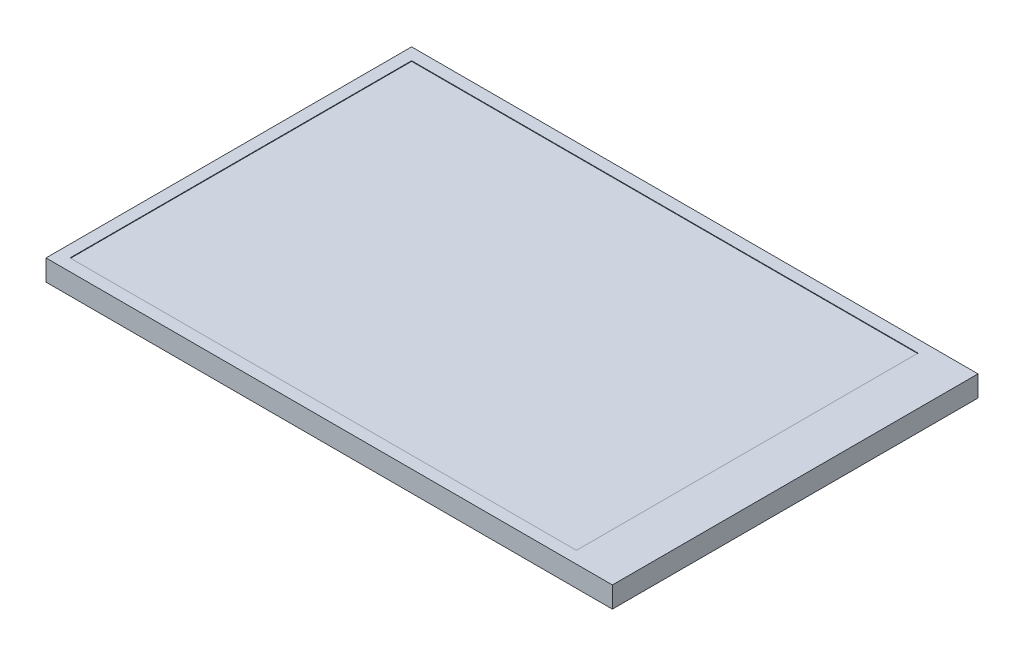
from build123d import *

# Parameters (mm, degrees)
SKETCH1_W           = 94.5
SKETCH1_H           = 61
BOSS_EXTRUDE1_DEPTH = 3.5
SKETCH2_W           = 84.5
SKETCH2_H           = 57
CUT_EXTRUDE1_DEPTH  = 0.1


with BuildPart() as part:
    # Sketch1 → Boss-Extrude1 (new body)
    with BuildSketch(Plane(origin=(0, 0, 0), x_dir=(1, 0, 0), z_dir=(0, 1, 0))):
        Rectangle(SKETCH1_W, SKETCH1_H)
    extrude(amount=BOSS_EXTRUDE1_DEPTH)

    # Sketch2 → Cut-Extrude1 (cut)
    with BuildSketch(Plane(origin=(0, 3.5, 0), x_dir=(1, 0, 0), z_dir=(0, 1, 0))):
        with Locations((-3, 0)):
            Rectangle(SKETCH2_W, SKETCH2_H)
    extrude(amount=-CUT_EXTRUDE1_DEPTH, mode=Mode.SUBTRACT)


solid = part.part
